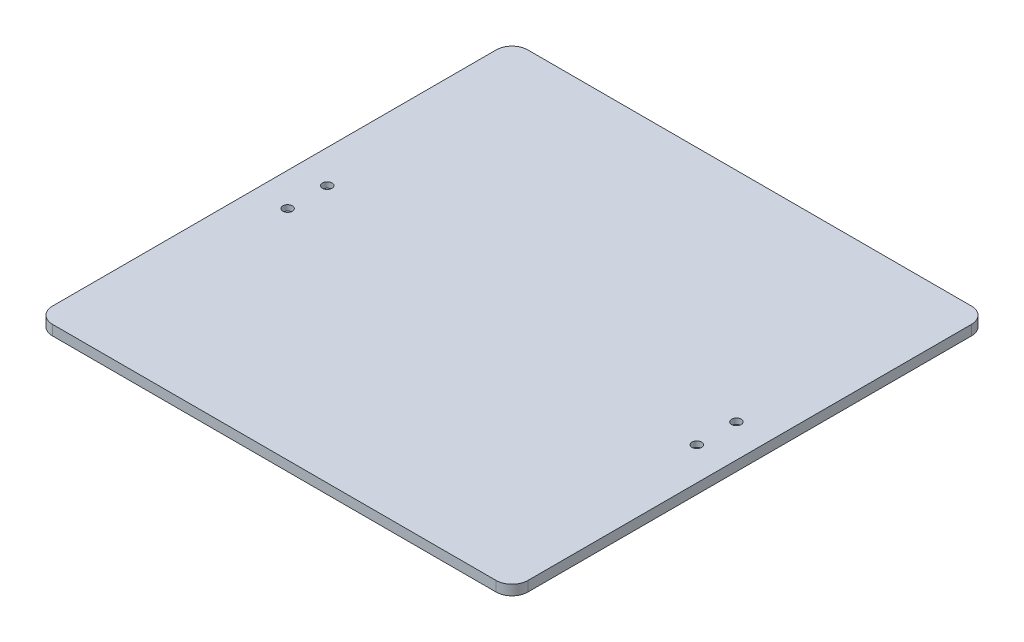
from build123d import *

# Parameters (mm, degrees)
SKETCH1_W            = 300
SKETCH1_H            = 300
BOSS_EXTRUDE1_DEPTH  = 6.35
FILLET1_R            = 10
SKETCH2_R            = 1.75
CUT_EXTRUDE1_DEPTH   = 7.35
SKETCH3_R            = 3
CUT_EXTRUDE2_DEPTH   = 3.5
LPATTERN1_COUNT      = 2
LPATTERN1_PITCH      = 25
LPATTERN1_COUNT_DIR2 = 2
LPATTERN1_PITCH_DIR2 = 258.24


with BuildPart() as part:
    # Sketch1 → Boss-Extrude1 (new body)
    with BuildSketch(Plane(origin=(0, 0, 0), x_dir=(1, 0, 0), z_dir=(0, 1, 0))):
        Rectangle(SKETCH1_W, SKETCH1_H)
    extrude(amount=BOSS_EXTRUDE1_DEPTH)

    # Fillet1
    fillet1_edges = [part.edges().sort_by_distance(p)[0] for p in [
        (150, 3.175, 150),
        (-150, 3.175, 150),
        (-150, 3.175, -150),
        (150, 3.175, -150),
    ]]
    fillet(fillet1_edges, radius=FILLET1_R)

    # Sketch2 → Cut-Extrude1 (cut, through all)
    with BuildSketch(Plane(origin=(0, 6.35, 0), x_dir=(1, 0, 0), z_dir=(0, 1, 0))):
        with Locations((-129.12, 12.5)):
            Circle(SKETCH2_R)
        with Locations((-129.12, -12.5)):
            Circle(SKETCH2_R)
        with Locations((129.12, 12.5)):
            Circle(SKETCH2_R)
        with Locations((129.12, -12.5)):
            Circle(SKETCH2_R)
    extrude(amount=-CUT_EXTRUDE1_DEPTH, mode=Mode.SUBTRACT)

    # Sketch3 → Cut-Extrude2 (cut)
    with BuildSketch(Plane(origin=(0, 6.35, 0), x_dir=(1, 0, 0), z_dir=(0, 1, 0))):
        with Locations((-129.12, 12.5)):
            Circle(SKETCH3_R)
    cut_extrude2 = extrude(amount=-CUT_EXTRUDE2_DEPTH, mode=Mode.SUBTRACT)

    # LPattern1: Cut-Extrude2 2 × 2
    with Locations(*[(j * LPATTERN1_PITCH_DIR2, 0, i * LPATTERN1_PITCH) for i in range(LPATTERN1_COUNT) for j in range(LPATTERN1_COUNT_DIR2) if (i, j) != (0, 0)]):
        add(cut_extrude2, mode=Mode.SUBTRACT)


solid = part.part
